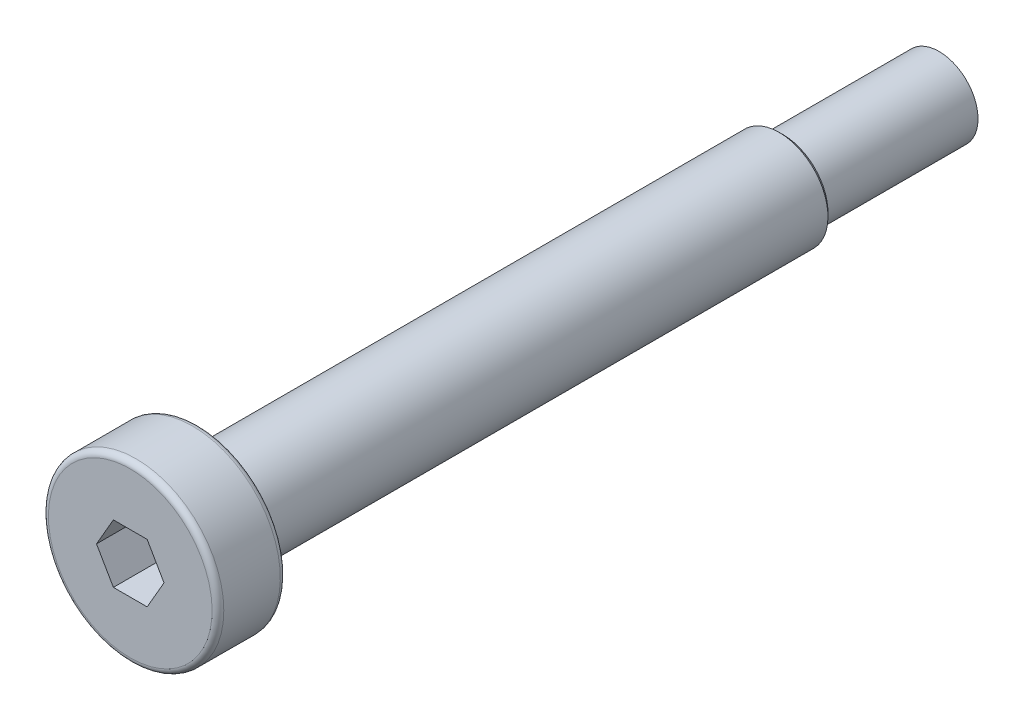
from build123d import *

# Parameters (mm, degrees)
FILLET_1_R          = 0.3
CUT_EXTRUDE_1_DEPTH = 2.4
CHAMFER_1_SIZE      = 0.2


with BuildPart() as part:
    # 草图1 → 旋转1 (revolve)
    with BuildSketch(Plane(origin=(0, 0, 0), x_dir=(0, 0, -1), z_dir=(1, 0, 0))):
        Polygon((0, 0), (0, 2), (-8, 2), (-8, 2.5), (-38, 2.5), (-38, 4.5), (-41.5, 4.5), (-41.5, 0), align=None)
    revolve(axis=Axis((0, 0, 0), (0, 0, 1)))

    # 圆角1
    fillet_1_edges = [part.edges().sort_by_distance(p)[0] for p in [
        (0, -4.5, 41.5),
        (0, -4.5, 38),
    ]]
    fillet(fillet_1_edges, radius=FILLET_1_R)

    # 草图2 → 切除-拉伸1 (cut)
    with BuildSketch(Plane.XY.offset(41.5)):
        Polygon((1.732050808, 0), (0.866025404, 1.5), (-0.866025404, 1.5), (-1.732050808, 0), (-0.866025404, -1.5), (0.866025404, -1.5), align=None)
    extrude(amount=-CUT_EXTRUDE_1_DEPTH, mode=Mode.SUBTRACT)

    # 倒角1
    chamfer_1_edges = [part.edges().sort_by_distance(p)[0] for p in [
        (0, -2.5, 8),
    ]]
    chamfer(chamfer_1_edges, length=CHAMFER_1_SIZE)


solid = part.part
